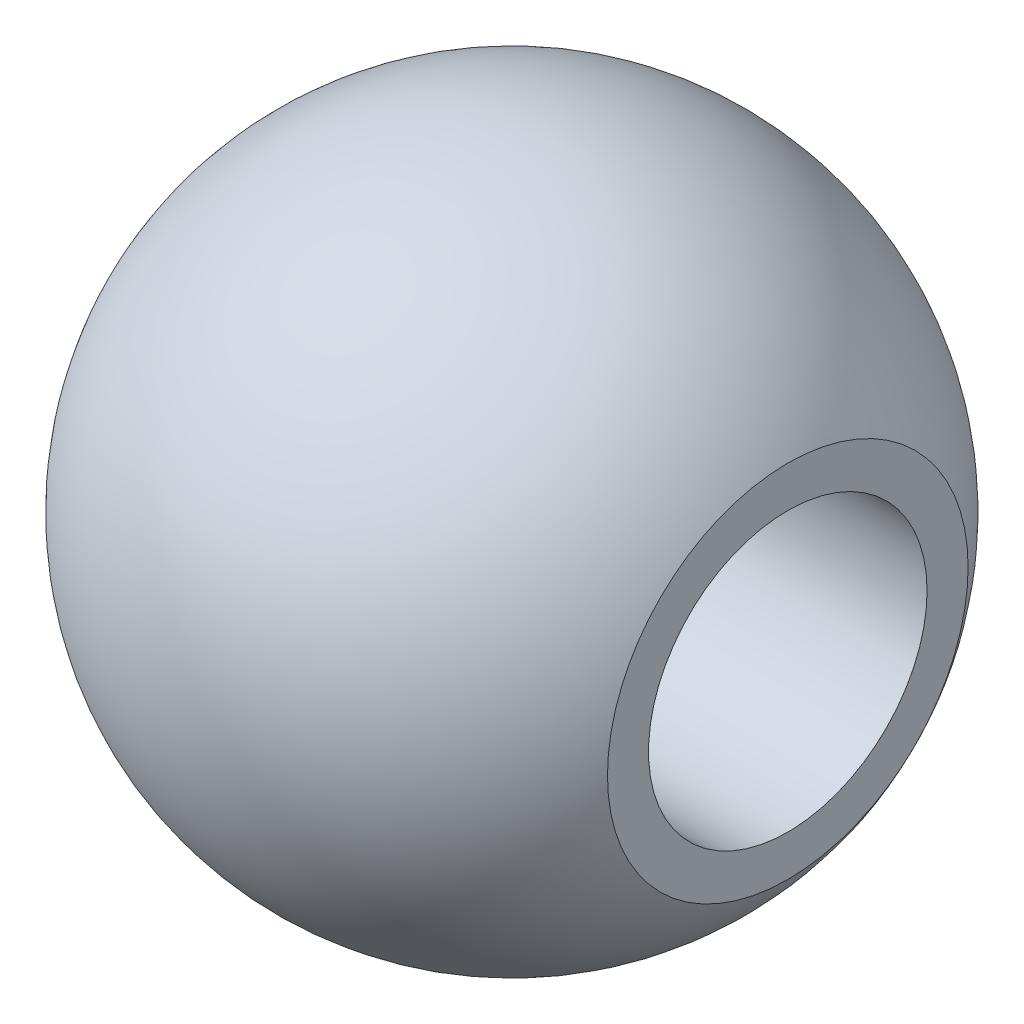
from build123d import *

# Parameters (mm, degrees)
SKETCH1_R           = 13.5
SKETCH1_R_2         = 11.2
BOSS_EXTRUDE1_DEPTH = 45
CIRPATTERN1_COUNT   = 8
LPATTERN1_COUNT     = 2
LPATTERN1_PITCH     = 20
FILLET1_R           = 2


with BuildPart() as part:
    # Sketch1 → Boss-Extrude1 (new body)
    with BuildSketch(Plane(origin=(0, 0, 0), x_dir=(0, 0, -1), z_dir=(1, 0, 0))):
        Circle(SKETCH1_R)
        Circle(SKETCH1_R_2, mode=Mode.SUBTRACT)
    extrude(amount=BOSS_EXTRUDE1_DEPTH)

    # Sketch2 → Cut-Revolve1 (revolve, cut)
    with BuildSketch(Plane.XY):
        with BuildLine():
            Line((5, 12.6), (5, 9.6))
            Line((5, 9.6), (8, 9.6))
            ThreePointArc((8, 9.6), (7.121320344, 11.721320344), (5, 12.6))
        make_face()
    cut_revolve1 = revolve(axis=Axis((5, 12.6, 0), (0, -1, 0)), mode=Mode.SUBTRACT)

    # CirPattern1: Cut-Revolve1 ×8 about axis
    cirpattern1_axis = Axis((0, 0, 0), (1, 0, 0))
    for i in range(1, CIRPATTERN1_COUNT):
        add(cut_revolve1.rotate(cirpattern1_axis, i * 360 / CIRPATTERN1_COUNT), mode=Mode.SUBTRACT)

    # LPattern1: Cut-Revolve1 ×2
    with Locations(*[(i * LPATTERN1_PITCH, 0, 0) for i in range(1, LPATTERN1_COUNT)]):
        add(cut_revolve1, mode=Mode.SUBTRACT)

    # LPattern1 copy 1 sketch → LPattern1 copy 1 (revolve, cut)
    with BuildSketch(Plane(origin=(20, 0, 0), x_dir=(1, 0, 0), z_dir=(0, -0.707106781, 0.707106781))):
        with BuildLine():
            Line((5, 12.6), (5, 9.6))
            Line((5, 9.6), (8, 9.6))
            ThreePointArc((8, 9.6), (7.121320344, 11.721320344), (5, 12.6))
        make_face()
    revolve(axis=Axis((25, 8.909545443, 8.909545443), (0, -0.707106781, -0.707106781)), mode=Mode.SUBTRACT)

    # LPattern1 copy 2 sketch → LPattern1 copy 2 (revolve, cut)
    with BuildSketch(Plane(origin=(20, 0, 0), x_dir=(1, 0, 0), z_dir=(0, -1, 0))):
        with BuildLine():
            Line((5, 12.6), (5, 9.6))
            Line((5, 9.6), (8, 9.6))
            ThreePointArc((8, 9.6), (7.121320344, 11.721320344), (5, 12.6))
        make_face()
    revolve(axis=Axis((25, 0, 12.6), (0, 0, -1)), mode=Mode.SUBTRACT)

    # LPattern1 copy 3 sketch → LPattern1 copy 3 (revolve, cut)
    with BuildSketch(Plane(origin=(20, 0, 0), x_dir=(1, 0, 0), z_dir=(0, -0.707106781, -0.707106781))):
        with BuildLine():
            Line((5, 12.6), (5, 9.6))
            Line((5, 9.6), (8, 9.6))
            ThreePointArc((8, 9.6), (7.121320344, 11.721320344), (5, 12.6))
        make_face()
    revolve(axis=Axis((25, -8.909545443, 8.909545443), (0, 0.707106781, -0.707106781)), mode=Mode.SUBTRACT)

    # LPattern1 copy 4 sketch → LPattern1 copy 4 (revolve, cut)
    with BuildSketch(Plane(origin=(20, 0, 0), x_dir=(1, 0, 0), z_dir=(0, 0, -1))):
        with BuildLine():
            Line((5, 12.6), (5, 9.6))
            Line((5, 9.6), (8, 9.6))
            ThreePointArc((8, 9.6), (7.121320344, 11.721320344), (5, 12.6))
        make_face()
    revolve(axis=Axis((25, -12.6, 0), (0, 1, 0)), mode=Mode.SUBTRACT)

    # LPattern1 copy 5 sketch → LPattern1 copy 5 (revolve, cut)
    with BuildSketch(Plane(origin=(20, 0, 0), x_dir=(1, 0, 0), z_dir=(0, 0.707106781, -0.707106781))):
        with BuildLine():
            Line((5, 12.6), (5, 9.6))
            Line((5, 9.6), (8, 9.6))
            ThreePointArc((8, 9.6), (7.121320344, 11.721320344), (5, 12.6))
        make_face()
    revolve(axis=Axis((25, -8.909545443, -8.909545443), (0, 0.707106781, 0.707106781)), mode=Mode.SUBTRACT)

    # LPattern1 copy 6 sketch → LPattern1 copy 6 (revolve, cut)
    with BuildSketch(Plane(origin=(20, 0, 0), x_dir=(1, 0, 0), z_dir=(0, 1, 0))):
        with BuildLine():
            Line((5, 12.6), (5, 9.6))
            Line((5, 9.6), (8, 9.6))
            ThreePointArc((8, 9.6), (7.121320344, 11.721320344), (5, 12.6))
        make_face()
    revolve(axis=Axis((25, 0, -12.6), (0, 0, 1)), mode=Mode.SUBTRACT)

    # LPattern1 copy 7 sketch → LPattern1 copy 7 (revolve, cut)
    with BuildSketch(Plane(origin=(20, 0, 0), x_dir=(1, 0, 0), z_dir=(0, 0.707106781, 0.707106781))):
        with BuildLine():
            Line((5, 12.6), (5, 9.6))
            Line((5, 9.6), (8, 9.6))
            ThreePointArc((8, 9.6), (7.121320344, 11.721320344), (5, 12.6))
        make_face()
    revolve(axis=Axis((25, 8.909545443, -8.909545443), (0, -0.707106781, 0.707106781)), mode=Mode.SUBTRACT)

    # Fillet1
    fillet1_edges = [part.edges().sort_by_distance(p)[0] for p in [
        (0, 0, 11.2),
    ]]
    fillet(fillet1_edges, radius=FILLET1_R)

    # Sketch3 → Revolve1 (revolve)
    with BuildSketch(Plane.XY):
        with BuildLine():
            Line((0, 13.5), (45, 13.5))
            Line((45, 13.5), (45, 14.5))
            ThreePointArc((45, 14.5), (22.222222222, 26.5), (0, 13.5))
        make_face()
    revolve(axis=Axis((0, 0, 0), (1, 0, 0)))


solid = part.part
